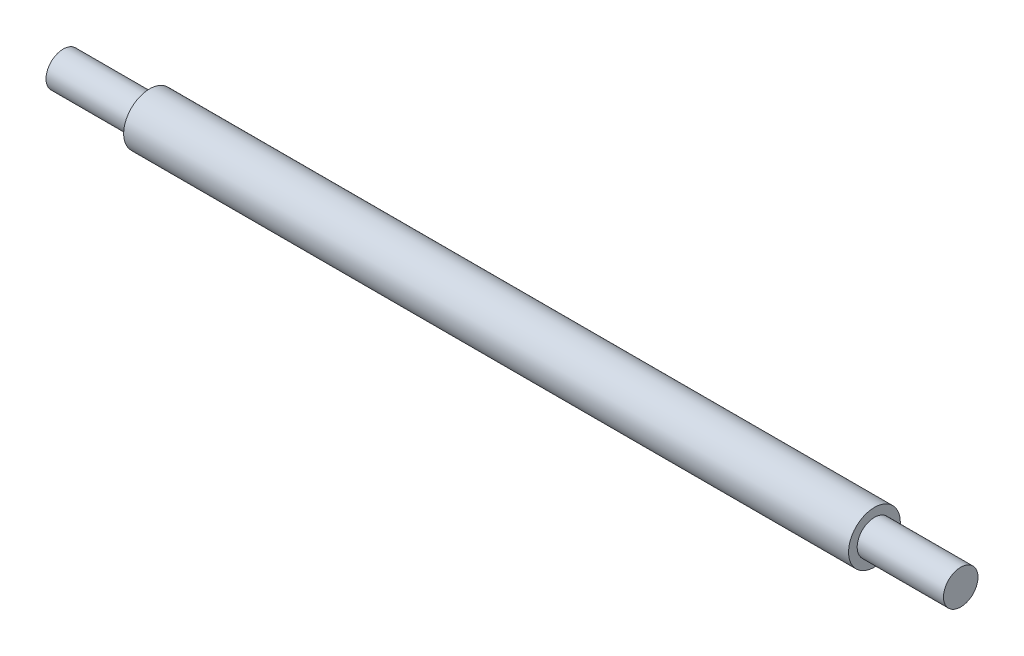
from build123d import *

# Parameters (mm, degrees)
SKETCH1_R           = 3
BOSS_EXTRUDE1_DEPTH = 84
SKETCH2_R           = 2
BOSS_EXTRUDE2_DEPTH = 10
SKETCH3_R           = 2
BOSS_EXTRUDE3_DEPTH = 10


with BuildPart() as part:
    # Sketch1 → Boss-Extrude1 (new body)
    with BuildSketch(Plane(origin=(0, 0, 0), x_dir=(0, 0, -1), z_dir=(1, 0, 0))):
        Circle(SKETCH1_R)
    extrude(amount=BOSS_EXTRUDE1_DEPTH)

    # Sketch2 → Boss-Extrude2 (add)
    with BuildSketch(Plane(origin=(84, 0, 0), x_dir=(0, 0, -1), z_dir=(1, 0, 0))):
        Circle(SKETCH2_R)
    extrude(amount=BOSS_EXTRUDE2_DEPTH)

    # Sketch3 → Boss-Extrude3 (add)
    with BuildSketch(Plane.ZY):
        Circle(SKETCH3_R)
    extrude(amount=BOSS_EXTRUDE3_DEPTH)


solid = part.part
